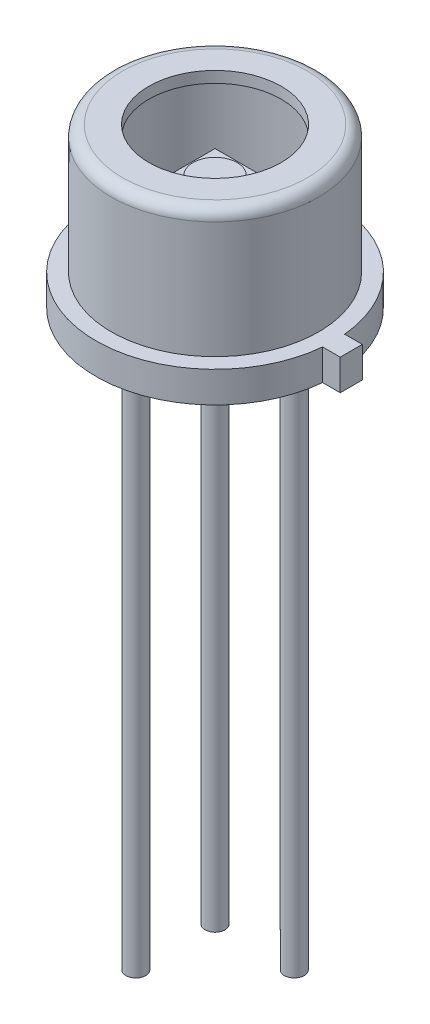
from build123d import *

# Parameters (mm, degrees)
SKETCH2_R           = 2.7
BOSS_EXTRUDE1_DEPTH = 0.446
BOSS_EXTRUDE2_START = -2.5
SKETCH3_W           = 1.25
SKETCH3_H           = 1.25
BOSS_EXTRUDE2_DEPTH = 0.05
SKETCH8_R           = 0.5
BOSS_EXTRUDE6_DEPTH = 0.1
BOSS_EXTRUDE8_DEPTH = 0.7
SKETCH5_R           = 0.225
BOSS_EXTRUDE4_DEPTH = 13


with BuildPart() as part:
    # Sketch1 → Revolve-Thin2 (revolve)
    with BuildSketch(Plane.XY, mode=Mode.PRIVATE) as revolve_thin2_sk:
        with BuildLine():
            Line((2.7, 0), (2.7, 0.7))
            Line((2.7, 0.7), (2.35, 0.7))
            Line((2.35, 0.7), (2.35, 3.346))
            ThreePointArc((2.35, 3.346), (2.275605122, 3.525605122), (2.096, 3.6))
            Line((2.096, 3.6), (1.5, 3.6))
            Line((1.5, 3.6), (1.5, 3.346))
            Line((1.5, 3.346), (2.096, 3.346))
            Line((2.096, 3.346), (2.096, 0.446))
            Line((2.096, 0.446), (2.446, 0.446))
            Line((2.446, 0.446), (2.446, 0))
            Line((2.446, 0), (2.7, 0))
        make_face()
    revolve(revolve_thin2_sk.sketch.rotate(Axis((0, 0, 0), (0, 1, 0)), 90), axis=Axis((0, 0, 0), (0, 1, 0)))  # turned: the seam where the file's is

    # Sketch2 → Boss-Extrude1 (add)
    with BuildSketch(Plane.XZ):
        with Locations(Location((0, 0, 0), (0, 0, 270))):  # turned: the seam where the file's is
            Circle(SKETCH2_R)
    extrude(amount=-BOSS_EXTRUDE1_DEPTH)

    # Sketch11 → Boss-Extrude8 (add)
    with BuildSketch(Plane.XZ):
        with BuildLine():
            Line((3.088401012, -0.25), (3.088401012, 0))
            Line((3.088401012, 0), (3.088401012, 0.25))
            Line((3.088401012, 0.25), (2.688401012, 0.25))
            ThreePointArc((2.688401012, 0.25), (2.697098694, 0.125134464), (2.7, 0))
            ThreePointArc((2.7, 0), (2.697098694, -0.125134464), (2.688401012, -0.25))
            Line((2.688401012, -0.25), (3.088401012, -0.25))
        make_face()
    extrude(amount=-BOSS_EXTRUDE8_DEPTH)

    # Sketch5 → Boss-Extrude4 (add)
    with BuildSketch(Plane.XZ):
        with Locations(Location((0.898025612, -0.898025612, 0), (0, 0, 90))):  # turned: the seam where the file's is
            Circle(SKETCH5_R)
        with Locations(Location((-0.898025612, 0.898025612, 0), (0, 0, 90))):  # turned: the seam where the file's is
            Circle(SKETCH5_R)
        with Locations(Location((-0.898025612, -0.898025612, 0), (0, 0, 90))):  # turned: the seam where the file's is
            Circle(SKETCH5_R)
    extrude(amount=BOSS_EXTRUDE4_DEPTH)


with BuildPart() as body_2:
    # Sketch3 → Boss-Extrude2 (new body)
    with BuildSketch(Plane.XZ.offset(BOSS_EXTRUDE2_START)):
        Rectangle(SKETCH3_W, SKETCH3_H)
    extrude(amount=BOSS_EXTRUDE2_DEPTH)

    # Sketch8 → Boss-Extrude6 (add)
    with BuildSketch(Plane(origin=(0, 2.5, 0), x_dir=(-1, 0, 0), z_dir=(0, 1, 0))):
        with Locations(Location((0, 0, 0), (0, 0, 270))):  # turned: the seam where the file's is
            Circle(SKETCH8_R)
    extrude(amount=BOSS_EXTRUDE6_DEPTH)


solid = Compound([part.part, body_2.part])
